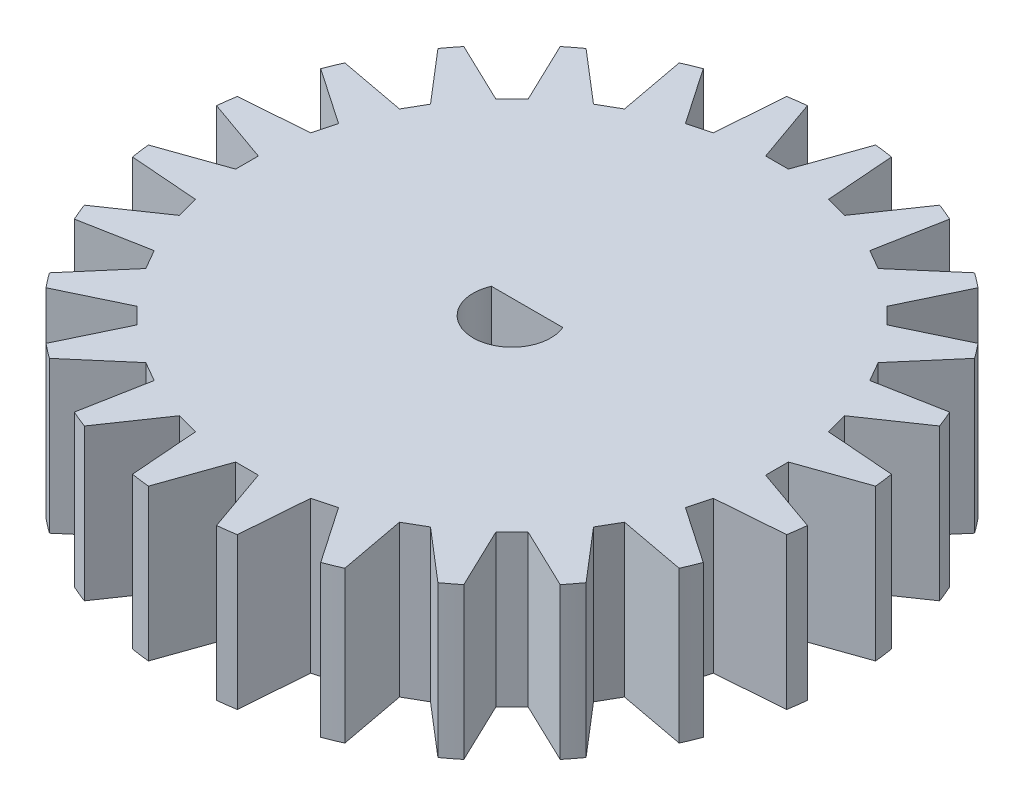
from build123d import *

# Parameters (mm, degrees)
SKETCH1_R           = 17.5
BOSS_EXTRUDE1_DEPTH = 8
CUT_EXTRUDE1_DEPTH  = 9
CUT_EXTRUDE2_DEPTH  = 10
CIRPATTERN1_COUNT   = 24


with BuildPart() as part:
    # Sketch1 → Boss-Extrude1 (new body)
    with BuildSketch(Plane(origin=(0, 0, 0), x_dir=(1, 0, 0), z_dir=(0, 1, 0))):
        Circle(SKETCH1_R)
    extrude(amount=BOSS_EXTRUDE1_DEPTH)

    # Sketch2 → Cut-Extrude1 (cut, through all)
    with BuildSketch(Plane(origin=(0, 8, 0), x_dir=(1, 0, 0), z_dir=(0, 1, 0))):
        with BuildLine():
            Line((-1.88867937, 0.797113692), (1.88867937, 0.797113692))
            ThreePointArc((1.88867937, 0.797113692), (0, -2.05), (-1.88867937, 0.797113692))
        make_face()
    extrude(amount=-CUT_EXTRUDE1_DEPTH, mode=Mode.SUBTRACT)

    # Sketch3 → Cut-Extrude2 (cut)
    with BuildSketch(Plane(origin=(0, 8, 0), x_dir=(1, 0, 0), z_dir=(0, 1, 0))):
        Polygon((0, 14), (0.6, 14), (1.8, 17.407182426), (1.8, 19.314701451), (-1.8, 19.314701451), (-1.8, 17.407182426), (-0.6, 14), align=None)
    cut_extrude2 = extrude(amount=-CUT_EXTRUDE2_DEPTH, mode=Mode.SUBTRACT)

    # CirPattern1: Cut-Extrude2 ×24 about axis
    cirpattern1_axis = Axis((0, 0, 0), (0, 1, 0))
    for i in range(1, CIRPATTERN1_COUNT):
        add(cut_extrude2.rotate(cirpattern1_axis, i * 360 / CIRPATTERN1_COUNT), mode=Mode.SUBTRACT)


solid = part.part
